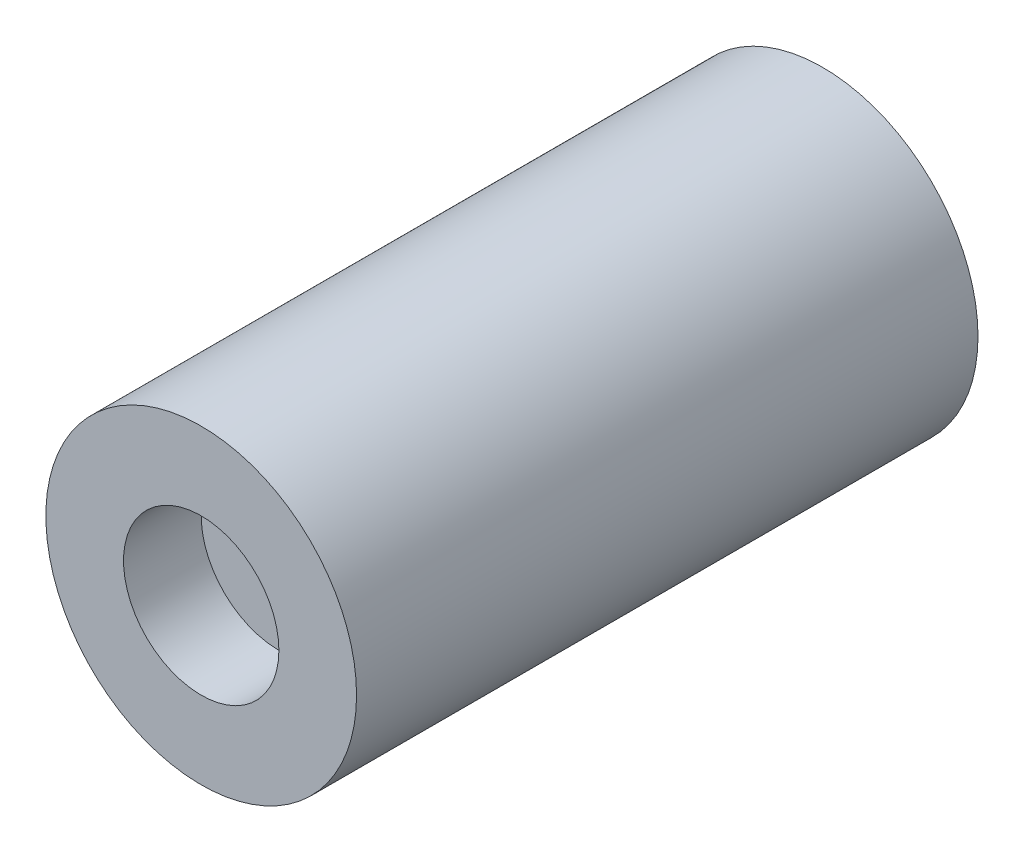
from build123d import *

# Parameters (mm, degrees)
ESQUISSE1_R             = 10
BOSS_EXTRU_1_DEPTH      = 40
ESQUISSE2_R             = 5
ENL_V_MAT_EXTRU_1_DEPTH = 5


with BuildPart() as part:
    # Esquisse1 → Boss.-Extru.1 (new body)
    with BuildSketch(Plane.XY):
        Circle(ESQUISSE1_R)
    extrude(amount=BOSS_EXTRU_1_DEPTH)

    # Esquisse2 → Enlèv. mat.-Extru.1 (cut)
    with BuildSketch(Plane.XY.offset(40)):
        Circle(ESQUISSE2_R)
    extrude(amount=-ENL_V_MAT_EXTRU_1_DEPTH, mode=Mode.SUBTRACT)


solid = part.part
